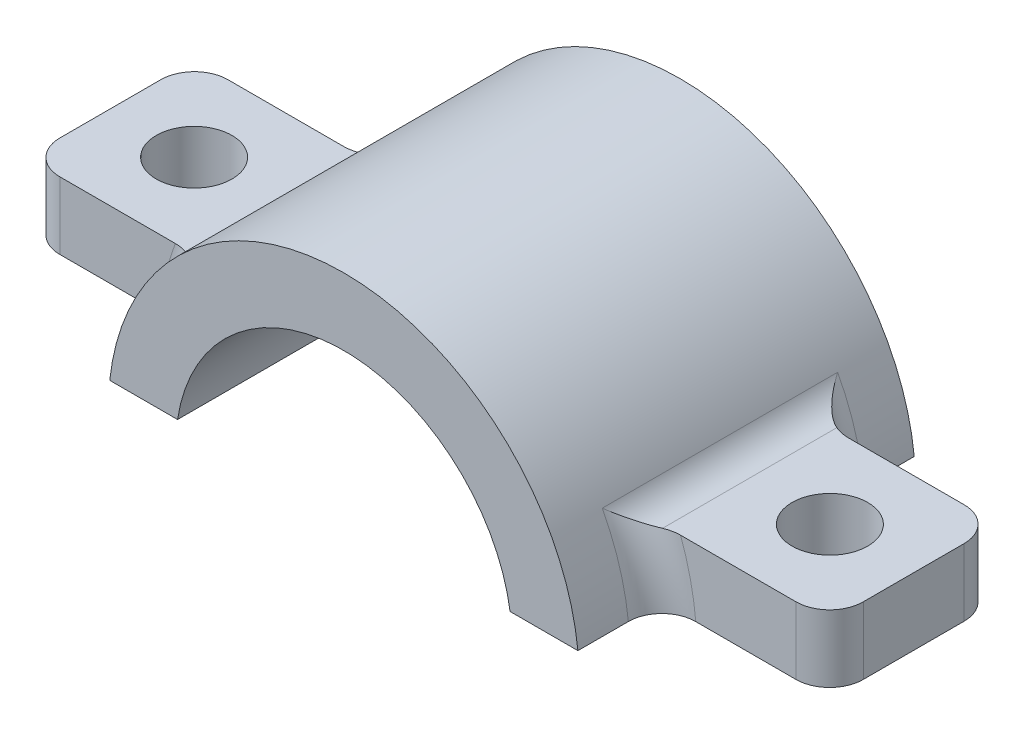
from build123d import *

# Parameters (mm, degrees)
BOSS_EXTRUDE1_DEPTH = 10
SKETCH2_W           = 14
SKETCH2_H           = 10
SKETCH2_R           = 2.25
BOSS_EXTRUDE2_DEPTH = 4
FILLET1_R           = 2


with BuildPart() as part:
    # Sketch1 → Boss-Extrude1 (new body, symmetric)
    with BuildSketch(Plane.XY):
        with BuildLine():
            Line((-13.919410907, 1.5), (-9.886859967, 1.5))
            ThreePointArc((-9.886859967, 1.5), (0, 10), (9.886859967, 1.5))
            Line((9.886859967, 1.5), (13.919410907, 1.5))
            ThreePointArc((13.919410907, 1.5), (0, 14), (-13.919410907, 1.5))
        make_face()
    extrude(amount=BOSS_EXTRUDE1_DEPTH, both=True)

    # Sketch2 → Boss-Extrude2 (add)
    with BuildSketch(Plane.XZ.offset(-1.5)):
        with Locations((16.886859967, 0)):
            Rectangle(SKETCH2_W, SKETCH2_H)
        with Locations((18.903135437, 0)):
            Circle(SKETCH2_R, mode=Mode.SUBTRACT)
        with Locations((-16.886859967, 0)):
            Rectangle(SKETCH2_W, SKETCH2_H)
        with Locations((-18.903135437, 0)):
            Circle(SKETCH2_R, mode=Mode.SUBTRACT)
    extrude(amount=-BOSS_EXTRUDE2_DEPTH)

    # Fillet1
    fillet1_edges = [part.edges().sort_by_distance(p)[0] for p in [
        (-12.87439319, 5.5, 0),
        (12.87439319, 5.5, 0),
        (13.54536764, 3.538787293, -5),
        (13.54536764, 3.538787293, 5),
        (23.886859967, 3.5, 5),
        (23.886859967, 3.5, -5),
        (-23.886859967, 3.5, 5),
        (-13.54536764, 3.538787293, -5),
        (-23.886859967, 3.5, -5),
        (-13.54536764, 3.538787293, 5),
    ]]
    fillet(fillet1_edges, radius=FILLET1_R)


solid = part.part
